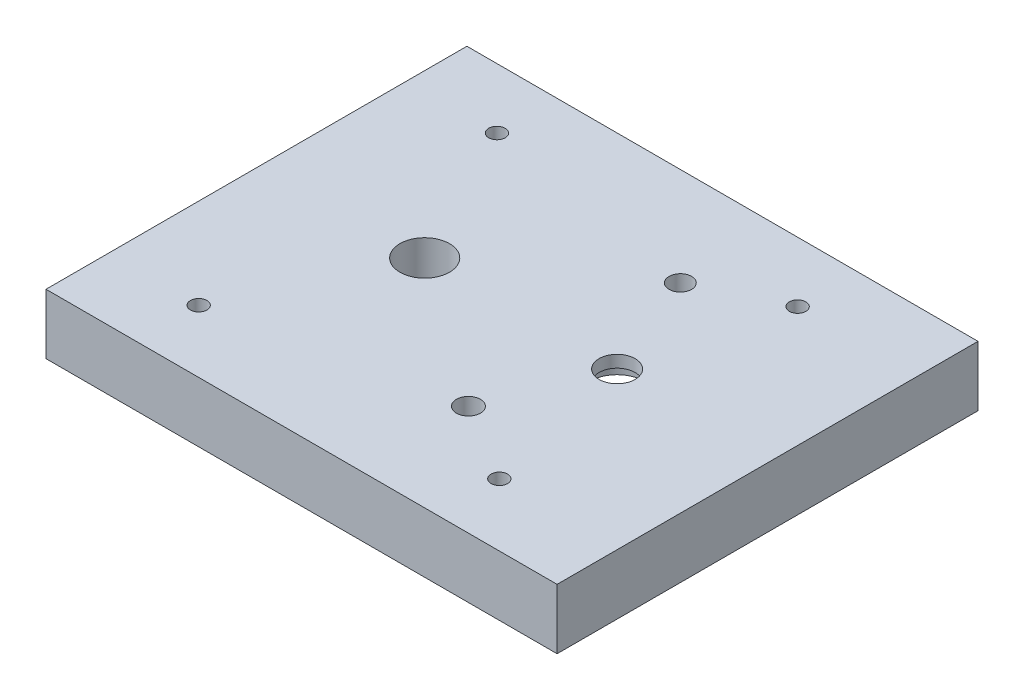
from build123d import *

# Parameters (mm, degrees)
SKETCH1_W           = 85
SKETCH1_H           = 70
SKETCH1_R           = 1.375
SKETCH1_R_2         = 1.875
SKETCH1_R_3         = 2
SKETCH1_W_2         = 2.231847436
SKETCH1_H_2         = 6.309819942
SKETCH1_R_4         = 4.125
SKETCH1_R_5         = 3
BOSS_EXTRUDE4_DEPTH = 10
SKETCH1_7_R         = 4.5
CUT_EXTRUDE2_DEPTH  = 6
SKETCH1_9_R         = 2
SKETCH1_9_R_2       = 1.875
SKETCH1_9_R_3       = 4.5
CUT_EXTRUDE6_DEPTH  = 6
SKETCH1_11_R        = 4.5
SKETCH1_11_R_2      = 3
CUT_EXTRUDE10_DEPTH = 8
SKETCH5_W           = 2.231847436
SKETCH5_H           = 6.309819942
BOSS_EXTRUDE5_DEPTH = 4


with BuildPart() as part:
    # Sketch1 → Boss-Extrude4 (new body)
    with BuildSketch(Plane(origin=(0, 0, 0), x_dir=(1, 0, 0), z_dir=(0, 1, 0))):
        Rectangle(SKETCH1_W, SKETCH1_H)
        with Locations((-27.5, -24.60667729)):
            Circle(SKETCH1_R, mode=Mode.SUBTRACT)
        with Locations((22.5, -24.60667729)):
            Circle(SKETCH1_R, mode=Mode.SUBTRACT)
        with Locations((-27.5, 25)):
            Circle(SKETCH1_R, mode=Mode.SUBTRACT)
        with Locations((22.5, 25)):
            Circle(SKETCH1_R, mode=Mode.SUBTRACT)
        with Locations((9.330885495, 18.664687396)):
            Circle(SKETCH1_R_2, mode=Mode.SUBTRACT)
        with Locations((9.474989645, -16.722600152)):
            Circle(SKETCH1_R_3, mode=Mode.SUBTRACT)
        with Locations((-8.615923718, 1)):
            Rectangle(SKETCH1_W_2, SKETCH1_H_2, mode=Mode.SUBTRACT)
        with Locations((-15.52, 1)):
            Circle(SKETCH1_R_4, mode=Mode.SUBTRACT)
        with Locations((16.478339488, 0.999882702)):
            Circle(SKETCH1_R_5, mode=Mode.SUBTRACT)
    extrude(amount=BOSS_EXTRUDE4_DEPTH)

    # Sketch1_7 → Cut-Extrude2 (cut)
    with BuildSketch(Plane(origin=(0, 0, 0), x_dir=(1, 0, 0), z_dir=(0, 1, 0))):
        with Locations((16.478339488, 0.999882702)):
            Circle(SKETCH1_7_R)
    extrude(amount=CUT_EXTRUDE2_DEPTH, mode=Mode.SUBTRACT)

    # Sketch1_9 → Cut-Extrude6 (cut)
    with BuildSketch(Plane(origin=(0, 0, 0), x_dir=(1, 0, 0), z_dir=(0, 1, 0))):
        with BuildLine():
            Line((12.955885495, 14.773048154), (12.955885495, 18.664687396))
            ThreePointArc((12.955885495, 18.664687396), (9.330885495, 22.289687396), (5.705885495, 18.664687396))
            Line((5.705885495, 18.664687396), (5.705885495, 14.683738346))
            ThreePointArc((5.705885495, 14.683738346), (0.761316141, 12.192649571), (-2.854756169, 8))
            Line((-2.854756169, 8), (-7.5, 8))
            Line((-7.5, 8), (-7.5, 4.154909971))
            Line((-7.5, 4.154909971), (-9.731847436, 4.154909971))
            Line((-9.731847436, 4.154909971), (-9.731847436, -2.154909971))
            Line((-9.731847436, -2.154909971), (-7.5, -2.154909971))
            Line((-7.5, -2.154909971), (-7.5, -6))
            Line((-7.5, -6), (-2.854756169, -6))
            ThreePointArc((-2.854756169, -6), (0.820287137, -10.238442268), (5.849989645, -12.722879596))
            Line((5.849989645, -12.722879596), (5.849989645, -16.722600152))
            ThreePointArc((5.849989645, -16.722600152), (9.474989645, -20.347600152), (13.099989645, -16.722600152))
            Line((13.099989645, -16.722600152), (13.099989645, -12.736086581))
            ThreePointArc((13.099989645, -12.736086581), (23.699805173, 1.074384413), (12.955885495, 14.773048154))
        make_face()
        with Locations((9.474989645, -16.722600152)):
            Circle(SKETCH1_9_R, mode=Mode.SUBTRACT)
        with Locations((9.330885495, 18.664687396)):
            Circle(SKETCH1_9_R_2, mode=Mode.SUBTRACT)
        with Locations((16.478339488, 0.999882702)):
            Circle(SKETCH1_9_R_3, mode=Mode.SUBTRACT)
    extrude(amount=CUT_EXTRUDE6_DEPTH, mode=Mode.SUBTRACT)

    # Sketch1_11 → Cut-Extrude10 (cut)
    with BuildSketch(Plane(origin=(0, 0, 0), x_dir=(1, 0, 0), z_dir=(0, 1, 0))):
        with Locations((16.478339488, 0.999882702)):
            Circle(SKETCH1_11_R)
        with Locations((16.478339488, 0.999882702)):
            Circle(SKETCH1_11_R_2, mode=Mode.SUBTRACT)
    extrude(amount=CUT_EXTRUDE10_DEPTH, mode=Mode.SUBTRACT)

    # Sketch5 → Boss-Extrude5 (add)
    with BuildSketch(Plane(origin=(0, 10, 0), x_dir=(1, 0, 0), z_dir=(0, 1, 0))):
        with Locations((-8.615923718, 1)):
            Rectangle(SKETCH5_W, SKETCH5_H)
    extrude(amount=-BOSS_EXTRUDE5_DEPTH)


solid = part.part
